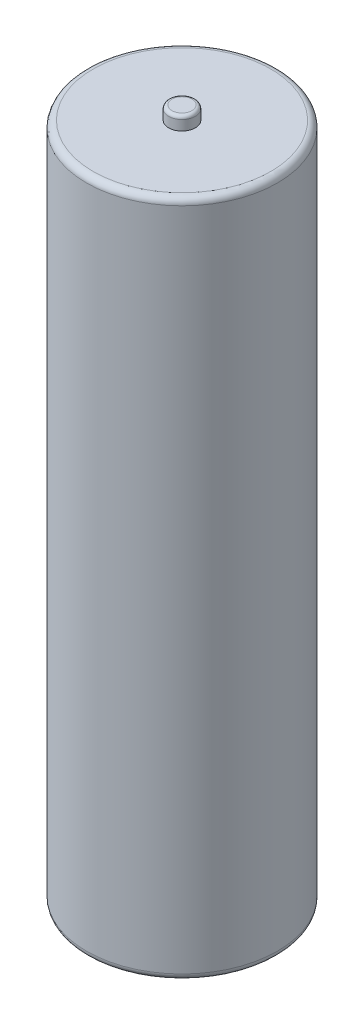
from build123d import *

# Parameters (mm, degrees)
SKETCH1_R           = 7.175
BOSS_EXTRUDE1_DEPTH = 51
FILLET1_R           = 0.5
SKETCH2_R           = 1
BOSS_EXTRUDE2_DEPTH = 1
FILLET2_R           = 0.25


with BuildPart() as part:
    # Sketch1 → Boss-Extrude1 (new body)
    with BuildSketch(Plane(origin=(0, 0, 0), x_dir=(1, 0, 0), z_dir=(0, 1, 0))):
        Circle(SKETCH1_R)
    extrude(amount=BOSS_EXTRUDE1_DEPTH)

    # Fillet1
    fillet1_edges = [part.edges().sort_by_distance(p)[0] for p in [
        (-7.175, 0, 0),
        (-7.175, 51, 0),
    ]]
    fillet(fillet1_edges, radius=FILLET1_R)

    # Sketch2 → Boss-Extrude2 (add)
    with BuildSketch(Plane(origin=(0, 51, 0), x_dir=(1, 0, 0), z_dir=(0, 1, 0))):
        Circle(SKETCH2_R)
    extrude(amount=BOSS_EXTRUDE2_DEPTH)

    # Fillet2
    fillet2_edges = [part.edges().sort_by_distance(p)[0] for p in [
        (-1, 52, 0),
    ]]
    fillet(fillet2_edges, radius=FILLET2_R)


solid = part.part
